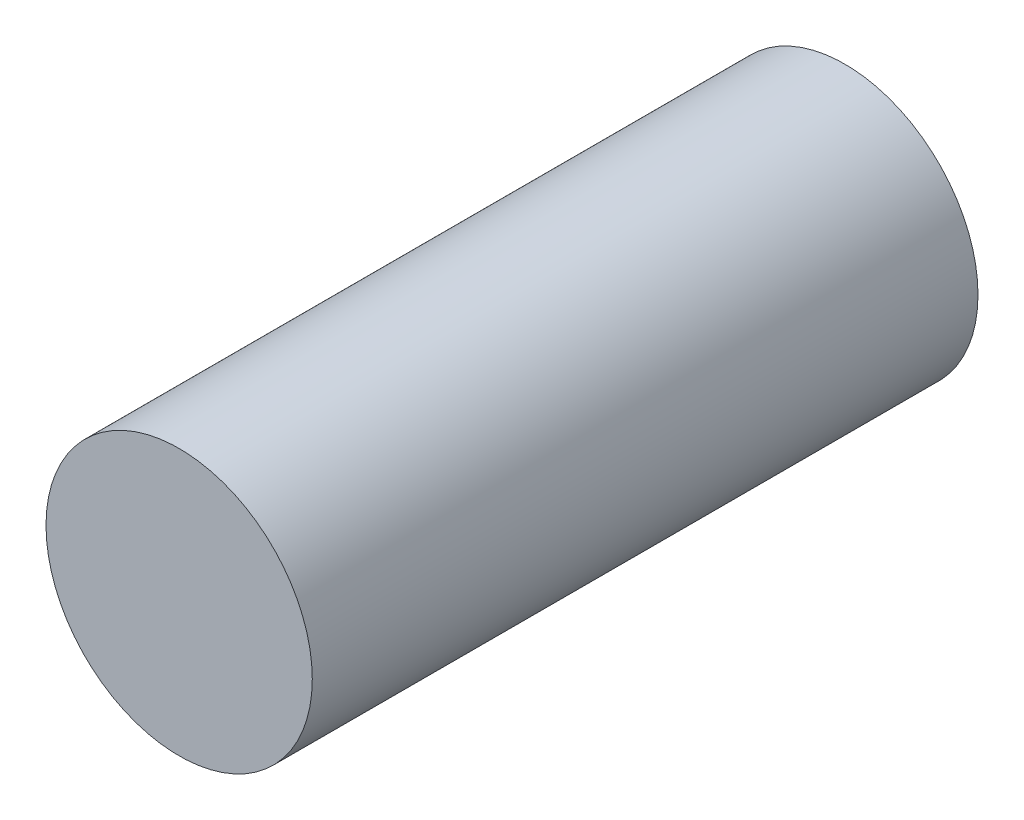
from build123d import *

# Parameters (mm, degrees)
SKETCH1_R           = 6.35
BOSS_EXTRUDE1_DEPTH = 31.75


with BuildPart() as part:
    # Sketch1 → Boss-Extrude1 (new body)
    with BuildSketch(Plane.XY):
        with Locations((-34.058343107, 35.901085714)):
            Circle(SKETCH1_R)
    extrude(amount=BOSS_EXTRUDE1_DEPTH)


solid = part.part
